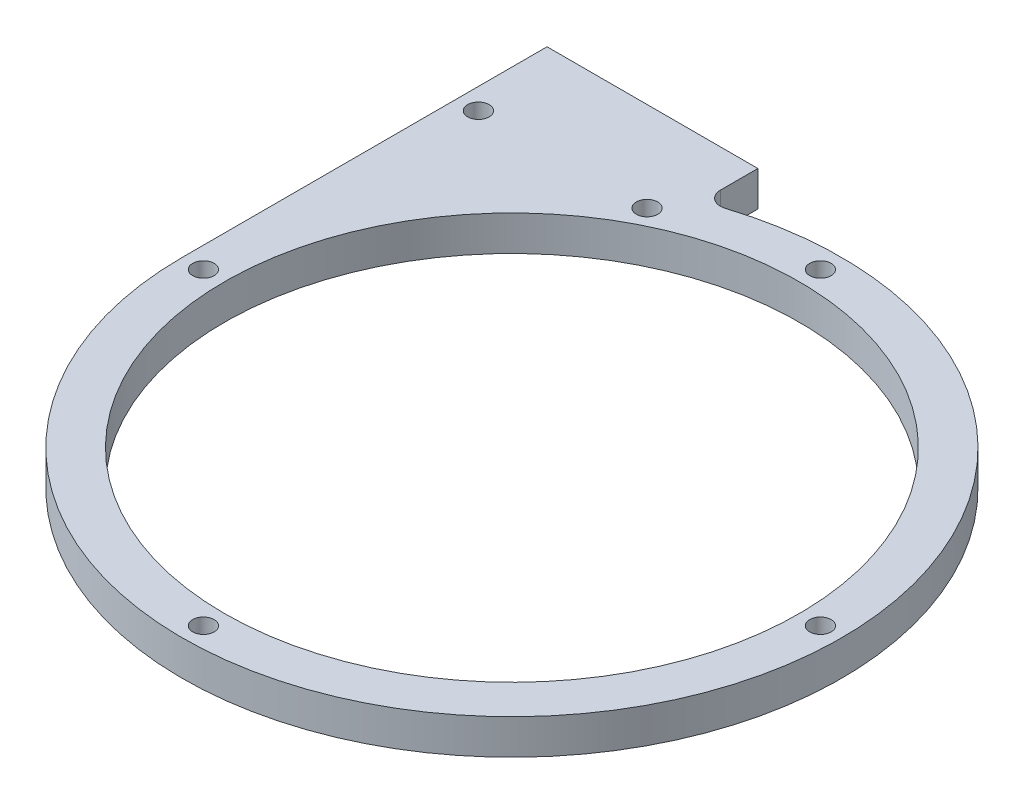
from build123d import *

# Parameters (mm, degrees)
SKETCH_1_R      = 40.9
SKETCH_1_R_2    = 1.525
EXTRUDE_1_DEPTH = 5
SKETCH_3_W      = 30
SKETCH_3_H      = 5
EXTRUDE_2_DEPTH = 5


with BuildPart() as part:
    # 草图1 → 凸台-拉伸1 (new body)
    with BuildSketch(Plane(origin=(0, 0, 0), x_dir=(1, 0, 0), z_dir=(0, 1, 0))):
        with BuildLine():
            Line((-46.9, 0), (-46.9, 46.9))
            Line((-46.9, 46.9), (-16.9, 46.9))
            Line((-16.9, 46.9), (-16.9, 46.574671228))
            ThreePointArc((-16.9, 46.574671228), (-16.079234093, 44.95930534), (-14.290593047, 44.669776699))
            ThreePointArc((-14.290593047, 44.669776699), (37.88033008, -27.65303949), (-46.9, 0))
        make_face()
        Circle(SKETCH_1_R, mode=Mode.SUBTRACT)
        with Locations((-19.9, 39.130550724)):
            Circle(SKETCH_1_R_2, mode=Mode.SUBTRACT)
        with Locations((0, 43.9)):
            Circle(SKETCH_1_R_2, mode=Mode.SUBTRACT)
        with Locations((43.9, 0)):
            Circle(SKETCH_1_R_2, mode=Mode.SUBTRACT)
        with Locations((0, -43.9)):
            Circle(SKETCH_1_R_2, mode=Mode.SUBTRACT)
        with Locations((-43.9, 0)):
            Circle(SKETCH_1_R_2, mode=Mode.SUBTRACT)
        with Locations((-43.9, 39.130550724)):
            Circle(SKETCH_1_R_2, mode=Mode.SUBTRACT)
    extrude(amount=EXTRUDE_1_DEPTH)

    # 草图3 → 凸台-拉伸2 (add)
    with BuildSketch(Plane(origin=(0, 0, 0), x_dir=(1, 0, 0), z_dir=(0, 1, 0))):
        with Locations((-31.9, 49.4)):
            Rectangle(SKETCH_3_W, SKETCH_3_H)
    extrude(amount=EXTRUDE_2_DEPTH)


solid = part.part
